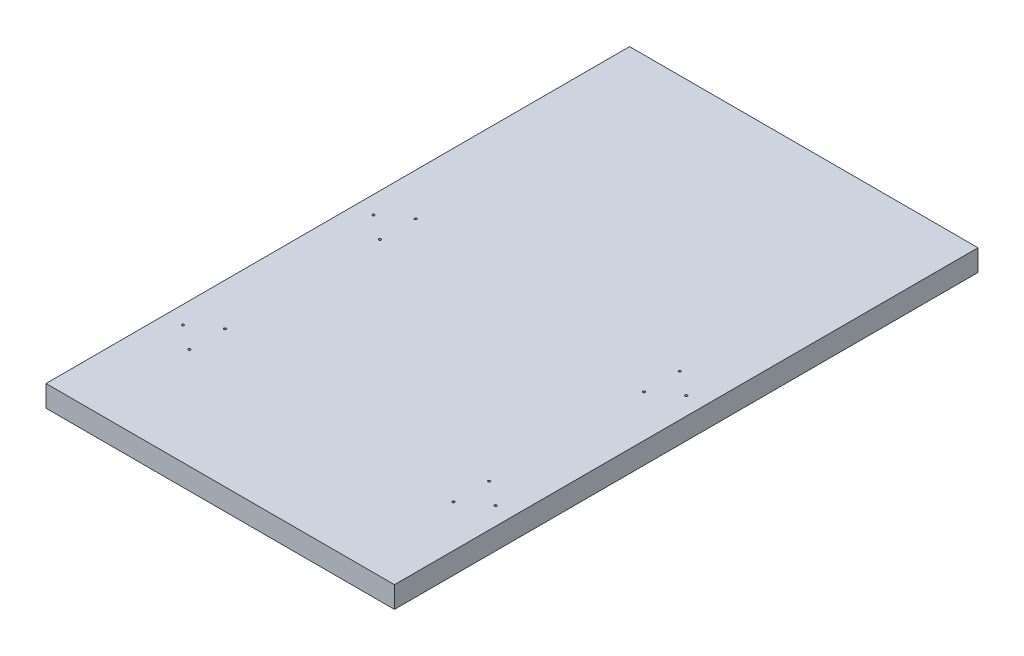
from build123d import *

# Parameters (mm, degrees)
SKETCH_1_W          = 400
SKETCH_1_H          = 240
EXTRUDE_1_DEPTH     = 18
SKETCH_2_R          = 1
CUT_EXTRUDE_1_DEPTH = 19
SKETCH_3_W          = 615.978672802
SKETCH_3_H          = 327.558551324
SKETCH_3_W_2        = 292.571526578
SKETCH_3_H_2        = 220
CUT_EXTRUDE_2_DEPTH = 19
SKETCH_4_W          = 292.571526578
SKETCH_4_H          = 18
EXTRUDE_2_DEPTH     = 200
SKETCH_5_W          = 292.571526578
SKETCH_5_H          = 18
EXTRUDE_3_DEPTH     = 70


with BuildPart() as part:
    # Эскиз1 → Бобышка-Вытянуть1 (new body)
    with BuildSketch(Plane(origin=(0, 0, 0), x_dir=(1, 0, 0), z_dir=(0, 1, 0))):
        with Locations((200, 120)):
            Rectangle(SKETCH_1_W, SKETCH_1_H)
    extrude(amount=EXTRUDE_1_DEPTH)

    # Эскиз2 → Вырез-Вытянуть1 (cut, through all)
    with BuildSketch(Plane(origin=(0, 18, 0), x_dir=(1, 0, 0), z_dir=(0, 1, 0))):
        with Locations((360.86, 55)):
            Circle(SKETCH_2_R)
        with Locations((360.86, 25)):
            Circle(SKETCH_2_R)
        with Locations((381.285763289, 40)):
            Circle(SKETCH_2_R)
        with Locations((118.714236711, 40)):
            Circle(SKETCH_2_R)
        with Locations((139.14, 25)):
            Circle(SKETCH_2_R)
        with Locations((139.14, 55)):
            Circle(SKETCH_2_R)
        with Locations((381.285763289, 200)):
            Circle(SKETCH_2_R)
        with Locations((360.86, 215)):
            Circle(SKETCH_2_R)
        with Locations((360.86, 185)):
            Circle(SKETCH_2_R)
        with Locations((139.14, 185)):
            Circle(SKETCH_2_R)
        with Locations((139.14, 215)):
            Circle(SKETCH_2_R)
        with Locations((118.714236711, 200)):
            Circle(SKETCH_2_R)
    extrude(amount=-CUT_EXTRUDE_1_DEPTH, mode=Mode.SUBTRACT)

    # Эскиз3 → Вырез-Вытянуть2 (cut, through all)
    with BuildSketch(Plane(origin=(0, 18, 0), x_dir=(1, 0, 0), z_dir=(0, 1, 0))):
        with Locations((196.616519556, 120.940245782)):
            Rectangle(SKETCH_3_W, SKETCH_3_H)
        with Locations((250, 120)):
            Rectangle(SKETCH_3_W_2, SKETCH_3_H_2, mode=Mode.SUBTRACT)
    extrude(amount=-CUT_EXTRUDE_2_DEPTH, mode=Mode.SUBTRACT)

    # Эскиз4 → Бобышка-Вытянуть2 (add)
    with BuildSketch(Plane(origin=(0, 0, -230), x_dir=(-1, 0, 0), z_dir=(0, 0, -1))):
        with Locations((-250, 9)):
            Rectangle(SKETCH_4_W, SKETCH_4_H)
    extrude(amount=EXTRUDE_2_DEPTH)

    # Эскиз5 → Бобышка-Вытянуть3 (add)
    with BuildSketch(Plane.XY.offset(-10)):
        with Locations((250, 9)):
            Rectangle(SKETCH_5_W, SKETCH_5_H)
    extrude(amount=EXTRUDE_3_DEPTH)


solid = part.part
